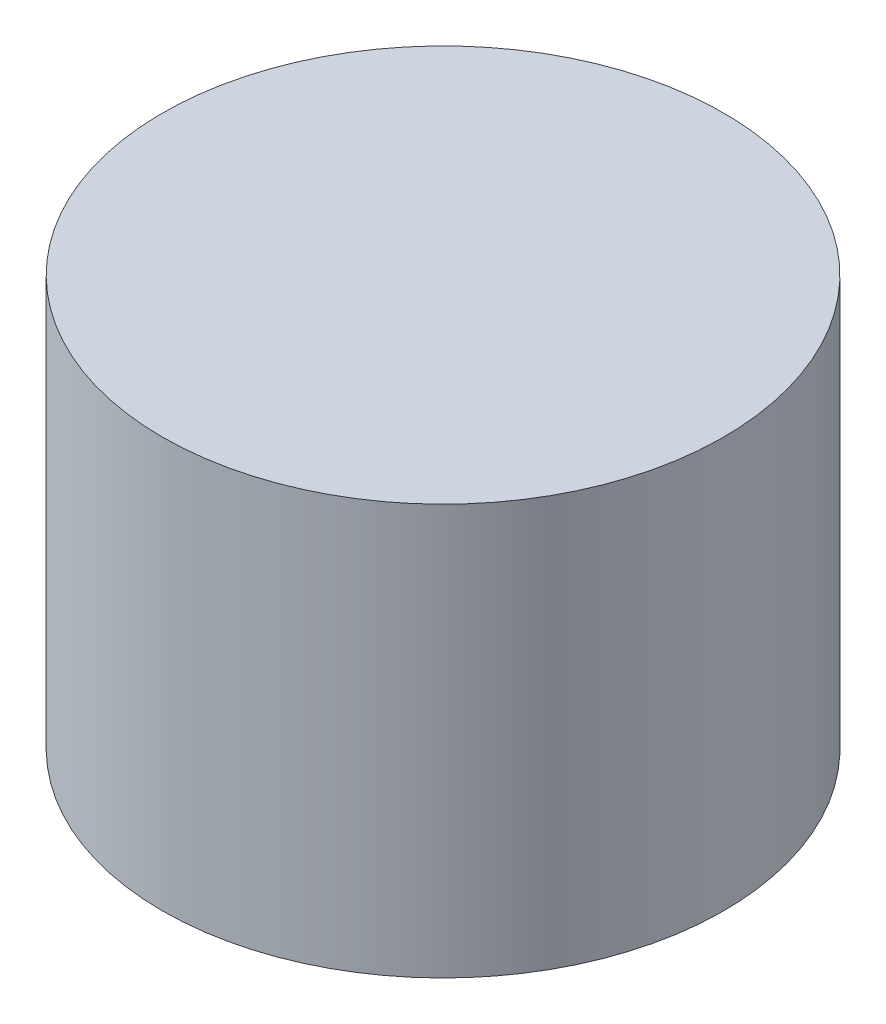
from build123d import *

# Parameters (mm, degrees)
SKETCH1_R           = 20.6375
BOSS_EXTRUDE1_DEPTH = 30.1752


with BuildPart() as part:
    # Sketch1 → Boss-Extrude1 (new body)
    with BuildSketch(Plane(origin=(0, 0, 0), x_dir=(1, 0, 0), z_dir=(0, 1, 0))):
        Circle(SKETCH1_R)
    extrude(amount=BOSS_EXTRUDE1_DEPTH)


solid = part.part
